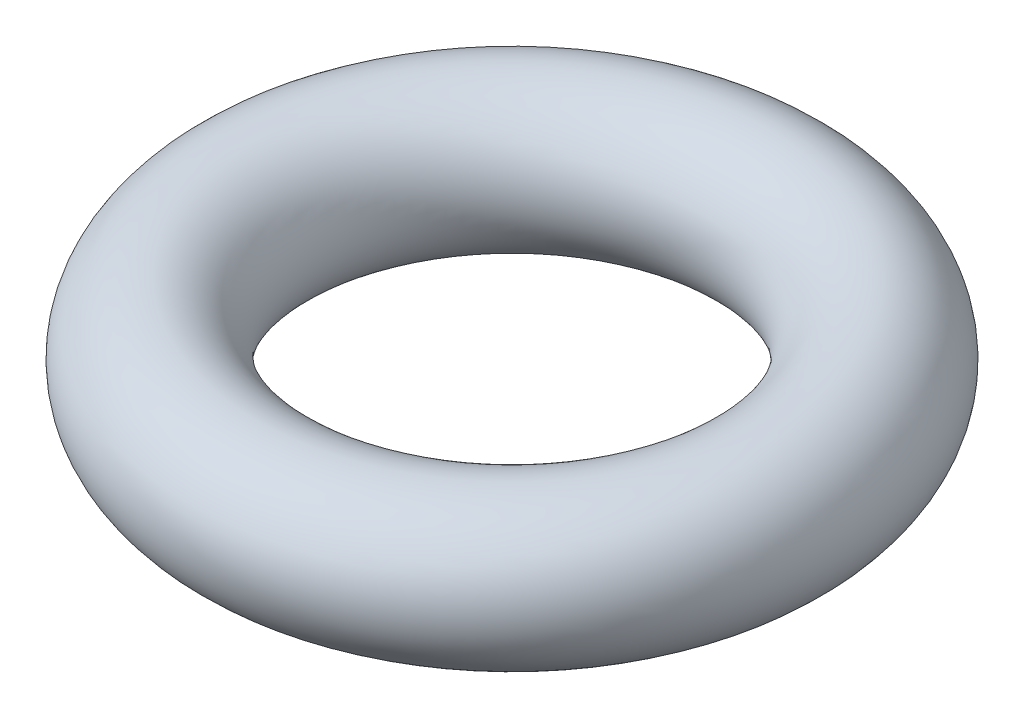
from build123d import *

# Parameters (mm, degrees)
SKETCH1_R = 1


with BuildPart() as part:
    # Sketch1 → Revolve1 (revolve)
    with BuildSketch(Plane.XY):
        with Locations((3.5, 0)):
            Circle(SKETCH1_R)
    revolve(axis=Axis((0, 0, 0), (0, 1, 0)))


solid = part.part
